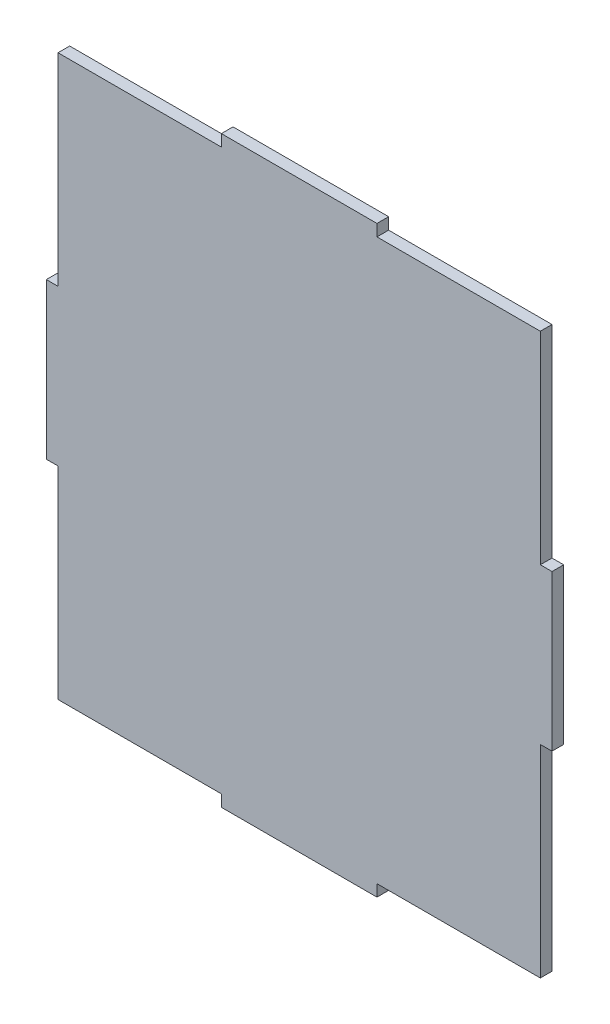
from build123d import *

# Parameters (mm, degrees)
ESBO_O2_W                = 124
ESBO_O2_H                = 144
ESBO_O2_W_2              = 3
ESBO_O2_H_2              = 40
ESBO_O2_W_3              = 40
ESBO_O2_H_3              = 3
RESSALTO_EXTRUS_O2_DEPTH = 3


with BuildPart() as part:
    # Esboço2 → Ressalto-extrusão2 (new body)
    with BuildSketch(Plane.XY):
        with Locations((1.546525062, -5.155083539)):
            Rectangle(ESBO_O2_W, ESBO_O2_H)
        with Locations((-61.953474938, -5.155083539)):
            Rectangle(ESBO_O2_W_2, ESBO_O2_H_2)
        with Locations((1.546525062, 68.344916461)):
            Rectangle(ESBO_O2_W_3, ESBO_O2_H_3)
        with Locations((65.046525062, -5.155083539)):
            Rectangle(ESBO_O2_W_2, ESBO_O2_H_2)
        with Locations((1.546525062, -78.655083539)):
            Rectangle(ESBO_O2_W_3, ESBO_O2_H_3)
    extrude(amount=RESSALTO_EXTRUS_O2_DEPTH)


solid = part.part
